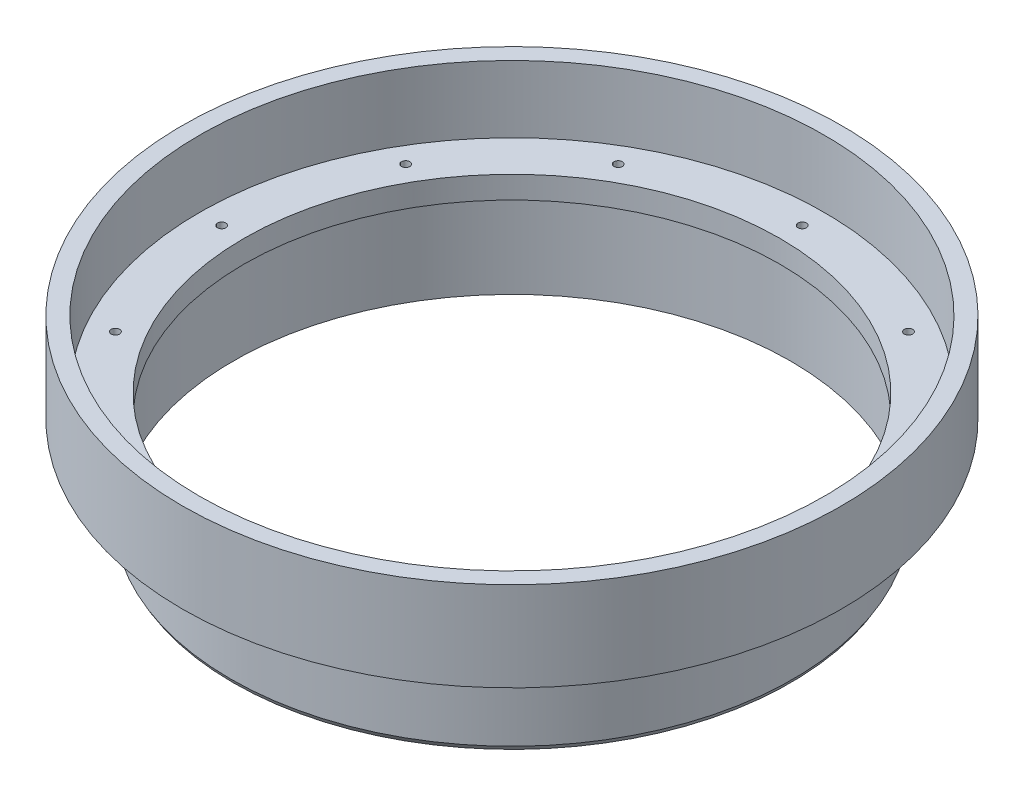
from build123d import *

# Parameters (mm, degrees)
SCREW_HOLES_COUNT = 12


with BuildPart() as part:
    # Cross Section → Main (revolve)
    with BuildSketch(Plane.XY):
        Polygon((-38.1, 0), (-38.1, -3.175), (-39.624, -3.175), (-39.624, -15.875), (-40.005, -15.215088642), (-40.005, -3.175), (-46.863, -3.175), (-46.863, 9.525), (-44.45, 9.525), (-44.45, 0), align=None)
    revolve(axis=Axis((0, 55, 0), (0, -1, 0)))

    # Sketch7 → #0-80 Tapped Hole1 (revolve, cut)
    with BuildSketch(Plane(origin=(-41.275, 0, 0), x_dir=(0, 0, 1), z_dir=(1, 0, 0))):
        Polygon((0, 0), (0, 3.532890611), (0.59563, 3.175), (0.59563, 0), align=None)
    f_0_80_tapped_hole1 = revolve(axis=Axis((-41.275, 6.35, 0), (0, -1, 0)), mode=Mode.SUBTRACT)

    # Screw Holes: #0-80 Tapped Hole1 ×12 about axis
    screw_holes_axis = Axis((0, 0, 0), (0, 1, 0))
    for i in range(1, SCREW_HOLES_COUNT):
        add(f_0_80_tapped_hole1.rotate(screw_holes_axis, i * 360 / SCREW_HOLES_COUNT), mode=Mode.SUBTRACT)


solid = part.part
